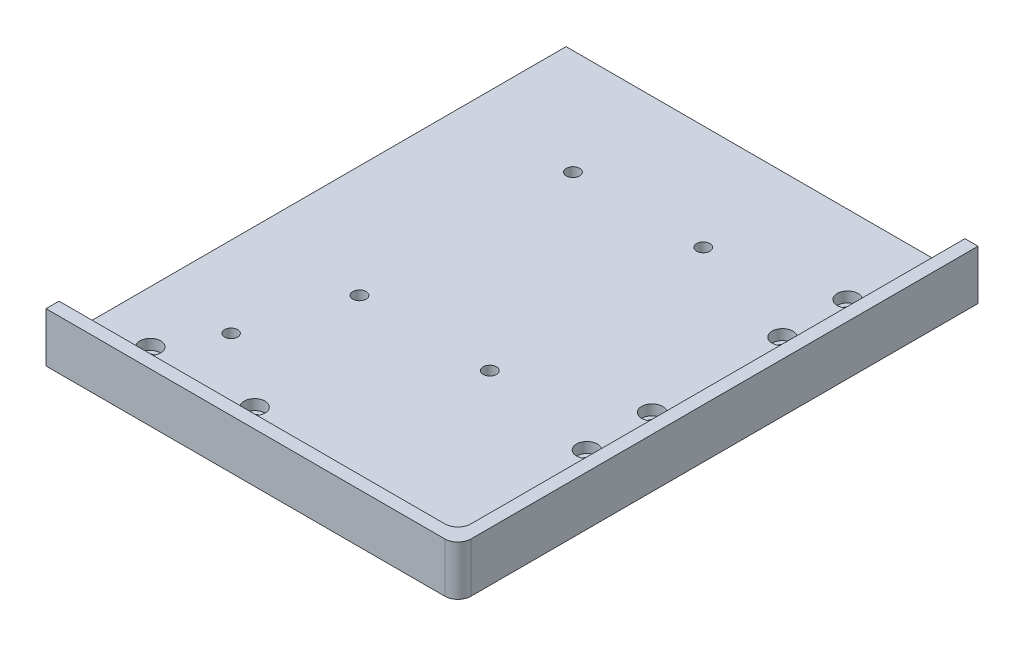
from build123d import *

# Parameters (mm, degrees)
SKETCH1_W                      = 158
SKETCH1_H                      = 199.5
BOSS_EXTRUDE1_DEPTH            = 6.35
BOSS_EXTRUDE2_DEPTH            = 12.7
CBORE_FOR_M4_SHCS1_D           = 4.5
CBORE_FOR_M4_SHCS1_DEPTH       = 6.35
CBORE_FOR_M4_SHCS1_CBORE_D     = 8
CBORE_FOR_M4_SHCS1_CBORE_DEPTH = 4
F_5_1_5_1_DIAMETER_HOLE1_D     = 5.1
F_5_1_5_1_DIAMETER_HOLE1_DEPTH = 6.35
FILLET2_R                      = 5
FILLET3_R                      = 5
F_5_0_5_DIAMETER_HOLE1_D       = 5
F_5_0_5_DIAMETER_HOLE1_DEPTH   = 6.35


with BuildPart() as part:
    # Sketch1 → Boss-Extrude1 (new body)
    with BuildSketch(Plane(origin=(0, 0, 0), x_dir=(1, 0, 0), z_dir=(0, 1, 0))):
        with Locations((79, -99.75)):
            Rectangle(SKETCH1_W, SKETCH1_H)
    extrude(amount=BOSS_EXTRUDE1_DEPTH)

    # Sketch3 → Boss-Extrude2 (add)
    with BuildSketch(Plane(origin=(0, 6.35, 0), x_dir=(1, 0, 0), z_dir=(0, 1, 0))):
        Polygon((158, -199.5), (158, 0), (153, 0), (153, -194.5), (0, -194.5), (0, -199.5), align=None)
    extrude(amount=BOSS_EXTRUDE2_DEPTH)

    # CBORE for M4 SHCS1
    with Locations(Plane(origin=(0, 6.35, 0), x_dir=(1, 0, 0), z_dir=(0, 1, 0))):
        with Locations((138, -55), (20, -179.5), (60, -179.5), (138, -130), (138, -105), (138, -30)):
            CounterBoreHole(CBORE_FOR_M4_SHCS1_D / 2, CBORE_FOR_M4_SHCS1_CBORE_D / 2, CBORE_FOR_M4_SHCS1_CBORE_DEPTH, depth=CBORE_FOR_M4_SHCS1_DEPTH)

    # Ø5.1 (5.1) Diameter Hole1
    with Locations(Plane(origin=(0, 6.35, 0), x_dir=(1, 0, 0), z_dir=(0, 1, 0))):
        with Locations((43, -40.38), (43, -122.25), (93, -122.25), (93, -40.38)):
            Hole(F_5_1_5_1_DIAMETER_HOLE1_D / 2, depth=F_5_1_5_1_DIAMETER_HOLE1_DEPTH)

    # Fillet2
    fillet2_edges = [part.edges().sort_by_distance(p)[0] for p in [
        (158, 9.525, 199.5),
    ]]
    fillet(fillet2_edges, radius=FILLET2_R)

    # Fillet3
    fillet3_edges = [part.edges().sort_by_distance(p)[0] for p in [
        (153, 12.7, 194.5),
    ]]
    fillet(fillet3_edges, radius=FILLET3_R)

    # Ø5.0 (5) Diameter Hole1
    with Locations(Plane(origin=(0, 6.35, 0), x_dir=(1, 0, 0), z_dir=(0, 1, 0))):
        with Locations((31, -159.5), (143, -159.5)):
            Hole(F_5_0_5_DIAMETER_HOLE1_D / 2, depth=F_5_0_5_DIAMETER_HOLE1_DEPTH)


solid = part.part
